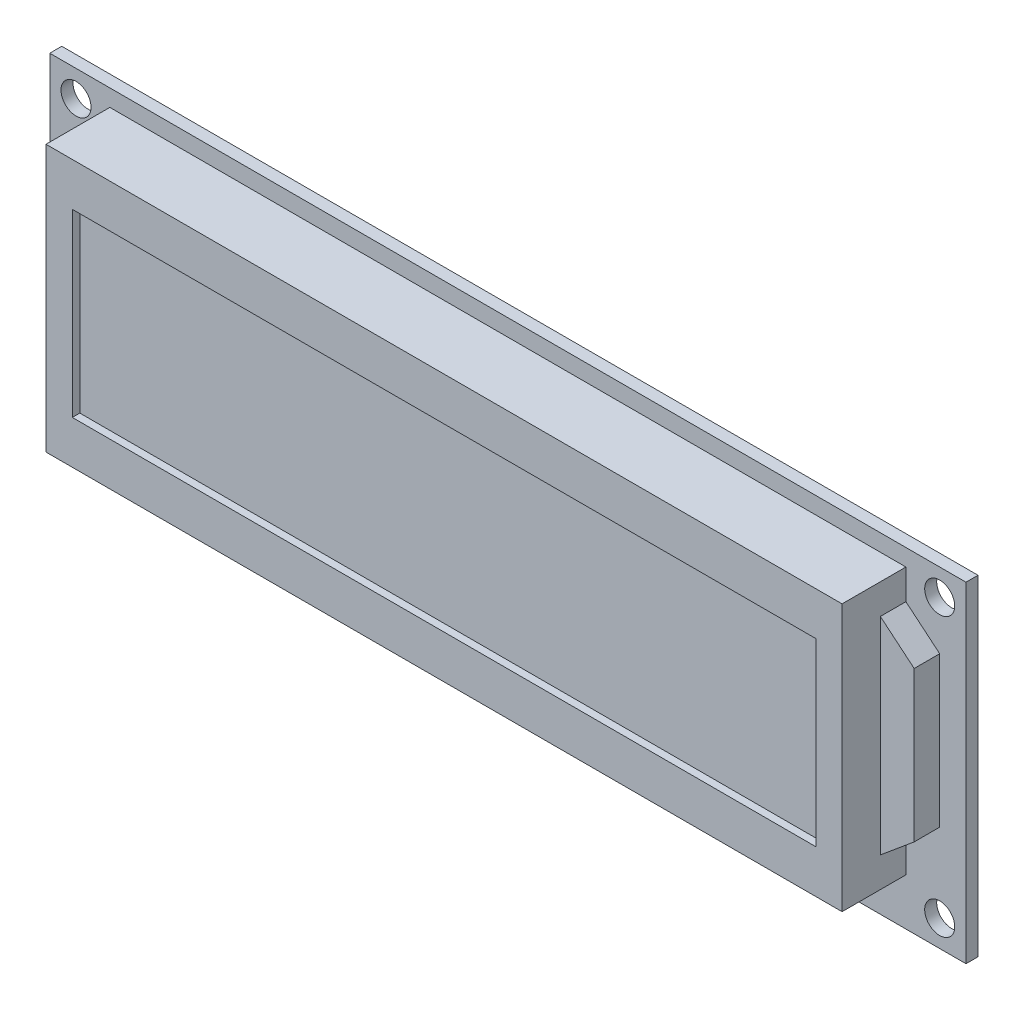
from build123d import *

# Parameters (mm, degrees)
SKETCH1_W           = 122
SKETCH1_H           = 44
SKETCH1_R           = 2
BOSS_EXTRUDE1_DEPTH = 1.6
SKETCH2_W           = 106
SKETCH2_H           = 35.5
BOSS_EXTRUDE2_DEPTH = 8.5
SKETCH4_W           = 99
SKETCH4_H           = 24
CUT_EXTRUDE1_DEPTH  = 1
BOSS_EXTRUDE3_DEPTH = 3.4


with BuildPart() as part:
    # Sketch1 → Boss-Extrude1 (new body)
    with BuildSketch(Plane.XY):
        Rectangle(SKETCH1_W, SKETCH1_H)
        with Locations((-57.5, 18.5)):
            Circle(SKETCH1_R, mode=Mode.SUBTRACT)
        with Locations((-57.5, -18.5)):
            Circle(SKETCH1_R, mode=Mode.SUBTRACT)
        with Locations((57.5, 18.5)):
            Circle(SKETCH1_R, mode=Mode.SUBTRACT)
        with Locations((57.5, -18.5)):
            Circle(SKETCH1_R, mode=Mode.SUBTRACT)
    extrude(amount=BOSS_EXTRUDE1_DEPTH)

    # Sketch2 → Boss-Extrude2 (add)
    with BuildSketch(Plane.XY.offset(1.6)):
        with Locations((0, 2)):
            Rectangle(SKETCH2_W, SKETCH2_H)
    extrude(amount=BOSS_EXTRUDE2_DEPTH)

    # Sketch4 → Cut-Extrude1 (cut)
    with BuildSketch(Plane.XY.offset(10.1)):
        with Locations((0, 2)):
            Rectangle(SKETCH4_W, SKETCH4_H)
    extrude(amount=-CUT_EXTRUDE1_DEPTH, mode=Mode.SUBTRACT)

    # Sketch5 → Boss-Extrude3 (add)
    with BuildSketch(Plane.XY.offset(1.6)):
        Polygon((53, 15.75), (53, -11.75), (57.5, -8), (57.5, 12), align=None)
    extrude(amount=BOSS_EXTRUDE3_DEPTH)


solid = part.part
